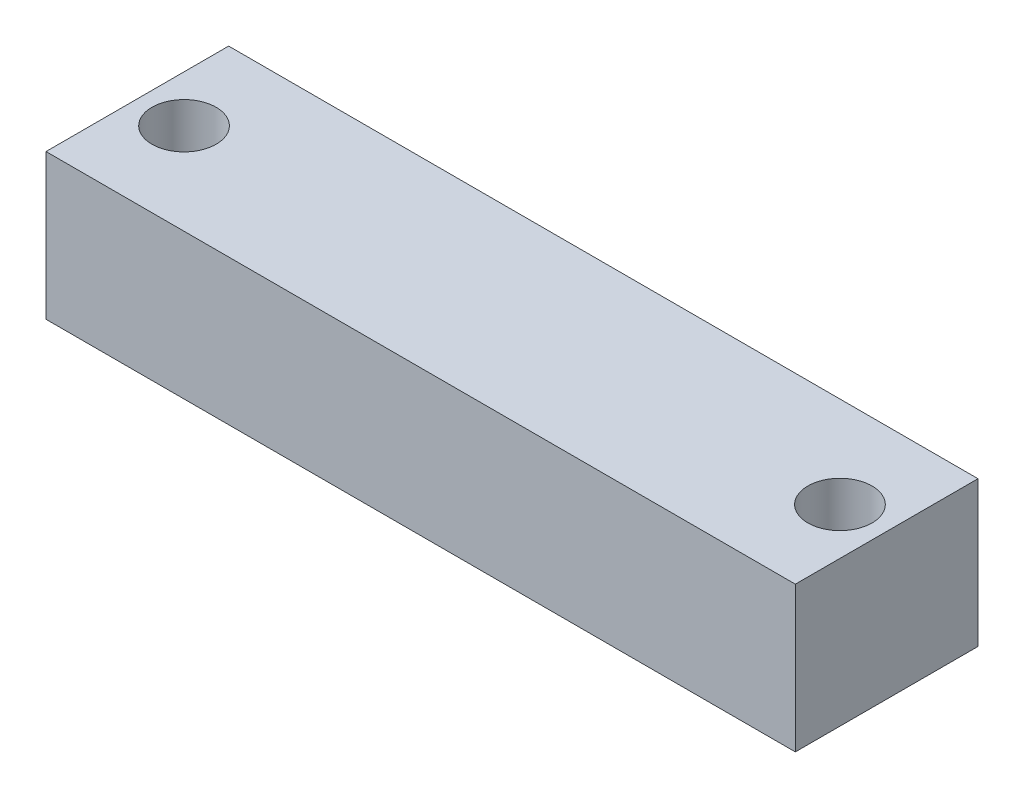
from build123d import *

# Parameters (mm, degrees)
SKETCH1_W               = 90.25
SKETCH1_H               = 22
BOSS_EXTRUDE1_DEPTH     = 17.5
SKETCH2_R               = 1.5
CUT_EXTRUDE1_DEPTH      = 1
CUT_EXTRUDE1_DEPTH_BACK = 18.5
SKETCH3_R               = 3.865
SKETCH3_R_2             = 1.5
CUT_EXTRUDE2_DEPTH      = 10


with BuildPart() as part:
    # Sketch1 → Boss-Extrude1 (new body)
    with BuildSketch(Plane(origin=(0, 0, 0), x_dir=(1, 0, 0), z_dir=(0, 1, 0))):
        Rectangle(SKETCH1_W, SKETCH1_H)
    extrude(amount=BOSS_EXTRUDE1_DEPTH)

    # Sketch2 → Cut-Extrude1 (cut, two sides)
    with BuildSketch(Plane(origin=(0, 17.5, 0), x_dir=(1, 0, 0), z_dir=(0, 1, 0))) as cut_extrude1_sk:
        with Locations((-39.5, 0)):
            Circle(SKETCH2_R)
        with Locations((39.5, 0)):
            Circle(SKETCH2_R)
    extrude(amount=CUT_EXTRUDE1_DEPTH, mode=Mode.SUBTRACT)
    extrude(cut_extrude1_sk.sketch, amount=-CUT_EXTRUDE1_DEPTH_BACK, mode=Mode.SUBTRACT)

    # Sketch3 → Cut-Extrude2 (cut)
    with BuildSketch(Plane(origin=(0, 17.5, 0), x_dir=(1, 0, 0), z_dir=(0, 1, 0))):
        with Locations((-39.5, 0)):
            Circle(SKETCH3_R)
        with Locations((-39.5, 0)):
            Circle(SKETCH3_R_2, mode=Mode.SUBTRACT)
        with Locations((39.5, 0)):
            Circle(SKETCH3_R)
        with Locations((39.5, 0)):
            Circle(SKETCH3_R_2, mode=Mode.SUBTRACT)
    extrude(amount=-CUT_EXTRUDE2_DEPTH, mode=Mode.SUBTRACT)


solid = part.part
